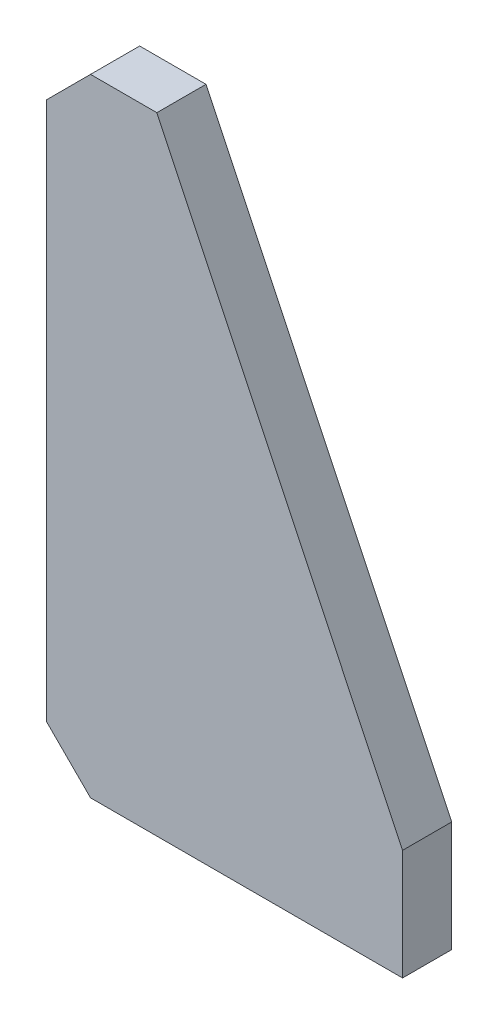
from build123d import *

# Parameters (mm, degrees)
EXTRUDE_1_DEPTH = 20
CHAMFER_1_SIZE  = 18


with BuildPart() as part:
    # Эскиз1 → Бобышка-Вытянуть1 (new body)
    with BuildSketch(Plane.XY):
        Polygon((0, 0), (0, 45), (-100, 255), (-127, 255), (-145, 237), (-145, 0), align=None)
    extrude(amount=EXTRUDE_1_DEPTH)

    # Фаска1
    chamfer_1_edges = [part.edges().sort_by_distance(p)[0] for p in [
        (-145, 0, 10),
    ]]
    chamfer(chamfer_1_edges, length=CHAMFER_1_SIZE)


solid = part.part
